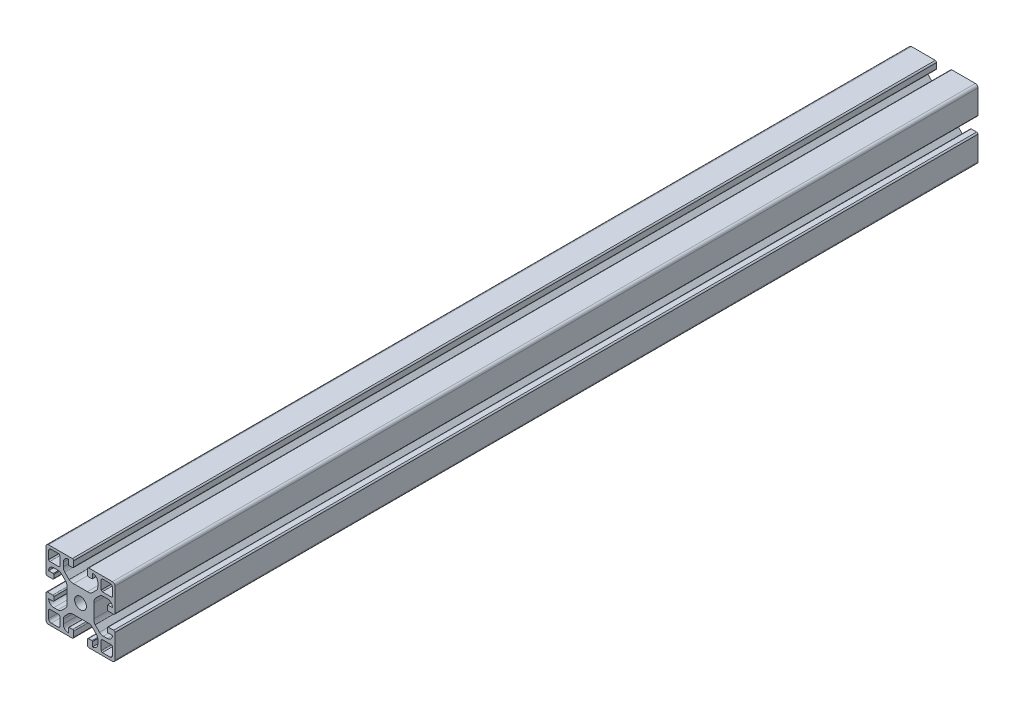
from build123d import *

# Parameters (mm, degrees)
CROQUIS1_R              = 3.4
SALIENTE_EXTRUIR1_DEPTH = 500


with BuildPart() as part:
    # Croquis1 → Saliente-Extruir1 (new body)
    with BuildSketch(Plane.XY):
        with BuildLine():
            ThreePointArc((1.5, 20), (0.439339828, 19.560660172), (0, 18.5))
            Line((0, 18.5), (0, 4.723246277))
            add(Edge.make_bspline(
                [(0, 4.723246277), (0.16818163, 4.15421854), (0.776519027, 4)],
                knots=[0, 0, 0, 1, 1, 1], degree=2))
            Line((0.776519027, 4), (3.876499959, 4))
            add(Edge.make_bspline(
                [(3.876499959, 4), (4.428343851, 4.075321958), (4.5, 4.561581647)],
                knots=[0, 0, 0, 0.770148696, 0.770148696, 0.770148696], degree=2))
            Line((4.5, 4.561581647), (4.5, 4.888433939))
            Line((4.5, 4.888433939), (4.5, 6.675480873))
            add(Edge.make_bspline(
                [(4.226708403, 7), (4.442584391, 6.908044465), (4.5, 6.675480873)],
                knots=[0, 0, 0, 1, 1, 1], degree=2))
            Line((4.226708403, 7), (1.5, 7))
            ThreePointArc((1.5, 7), (2.378679656, 9.121320344), (4.5, 10))
            Line((4.5, 10), (6.795713853, 10))
            add(Edge.make_bspline(
                [(6.795713853, 10), (6.864922078, 10.001348654), (6.933119616, 10)],
                knots=[0, 0, 0, 0.053884422, 0.053884422, 0.053884422], degree=2))
            add(Edge.make_bspline(
                [(6.933119616, 10), (8.130548293, 9.976320018), (9.016390221, 9.121082451)],
                knots=[0.053884422, 0.053884422, 0.053884422, 1, 1, 1], degree=2))
            Line((9.016390221, 9.121082451), (11.507582012, 6.629890661))
            add(Edge.make_bspline(
                [(11.507582012, 6.629890661), (12.156952743, 5.772287934), (12.25, 4.723246277)],
                knots=[0, 0, 0, 0.74933997, 0.74933997, 0.74933997], degree=2))
            add(Edge.make_bspline(
                [(12.25, 4.723246277), (12.281125029, 4.37233371), (12.25, 4)],
                knots=[0.74933997, 0.74933997, 0.74933997, 1, 1, 1], degree=2))
            Line((12.25, 4), (12.25, -4))
            add(Edge.make_bspline(
                [(12.25, -4.723246277), (12.281125029, -4.37233371), (12.25, -4)],
                knots=[0.74933997, 0.74933997, 0.74933997, 1, 1, 1], degree=2))
            add(Edge.make_bspline(
                [(11.507582012, -6.629890661), (12.156952743, -5.772287934), (12.25, -4.723246277)],
                knots=[0, 0, 0, 0.74933997, 0.74933997, 0.74933997], degree=2))
            Line((11.507582012, -6.629890661), (9.016390221, -9.121082451))
            add(Edge.make_bspline(
                [(6.933119616, -10), (8.130548293, -9.976320018), (9.016390221, -9.121082451)],
                knots=[0.053884422, 0.053884422, 0.053884422, 1, 1, 1], degree=2))
            add(Edge.make_bspline(
                [(6.795713853, -10), (6.864922078, -10.001348654), (6.933119616, -10)],
                knots=[0, 0, 0, 0.053884422, 0.053884422, 0.053884422], degree=2))
            Line((6.795713853, -10), (4.5, -10))
            ThreePointArc((4.5, -10), (2.378679656, -9.121320344), (1.5, -7))
            Line((1.5, -7), (4.226708403, -7))
            add(Edge.make_bspline(
                [(4.226708403, -7), (4.442584391, -6.908044465), (4.5, -6.675480873)],
                knots=[0, 0, 0, 1, 1, 1], degree=2))
            Line((4.5, -6.675480873), (4.5, -4.888433939))
            Line((4.5, -4.888433939), (4.5, -4.561581647))
            add(Edge.make_bspline(
                [(3.876499959, -4), (4.428343851, -4.075321958), (4.5, -4.561581647)],
                knots=[0, 0, 0, 0.770148696, 0.770148696, 0.770148696], degree=2))
            Line((3.876499959, -4), (0.776519027, -4))
            add(Edge.make_bspline(
                [(0, -4.723246277), (0.16818163, -4.15421854), (0.776519027, -4)],
                knots=[0, 0, 0, 1, 1, 1], degree=2))
            Line((0, -4.723246277), (0, -18.5))
            ThreePointArc((0, -18.5), (0.439339828, -19.560660172), (1.5, -20))
            Line((1.5, -20), (15.276753723, -20))
            add(Edge.make_bspline(
                [(15.276753723, -20), (15.84578146, -19.83181837), (16, -19.223480973)],
                knots=[0, 0, 0, 1, 1, 1], degree=2))
            Line((16, -19.223480973), (16, -16.123500041))
            add(Edge.make_bspline(
                [(16, -16.123500041), (15.924678042, -15.571656149), (15.438418353, -15.5)],
                knots=[0, 0, 0, 0.770148696, 0.770148696, 0.770148696], degree=2))
            Line((15.438418353, -15.5), (15.111566061, -15.5))
            Line((15.111566061, -15.5), (13.324519127, -15.5))
            add(Edge.make_bspline(
                [(13, -15.773291597), (13.091955535, -15.557415609), (13.324519127, -15.5)],
                knots=[0, 0, 0, 1, 1, 1], degree=2))
            Line((13, -15.773291597), (13, -18.5))
            ThreePointArc((13, -18.5), (10.878679656, -17.621320344), (10, -15.5))
            Line((10, -15.5), (10, -13.204286147))
            add(Edge.make_bspline(
                [(10, -13.204286147), (9.998651346, -13.135077922), (10, -13.066880384)],
                knots=[0, 0, 0, 0.053884422, 0.053884422, 0.053884422], degree=2))
            add(Edge.make_bspline(
                [(10, -13.066880384), (10.023679982, -11.869451707), (10.878917549, -10.983609779)],
                knots=[0.053884422, 0.053884422, 0.053884422, 1, 1, 1], degree=2))
            Line((10.878917549, -10.983609779), (13.370109339, -8.492417988))
            add(Edge.make_bspline(
                [(13.370109339, -8.492417988), (14.227712066, -7.843047257), (15.276753723, -7.75)],
                knots=[0, 0, 0, 0.74933997, 0.74933997, 0.74933997], degree=2))
            add(Edge.make_bspline(
                [(15.276753723, -7.75), (15.62766629, -7.718874971), (16, -7.75)],
                knots=[0.74933997, 0.74933997, 0.74933997, 1, 1, 1], degree=2))
            Line((16, -7.75), (24, -7.75))
            add(Edge.make_bspline(
                [(24.723246277, -7.75), (24.37233371, -7.718874971), (24, -7.75)],
                knots=[0.74933997, 0.74933997, 0.74933997, 1, 1, 1], degree=2))
            add(Edge.make_bspline(
                [(26.629890661, -8.492417988), (25.772287934, -7.843047257), (24.723246277, -7.75)],
                knots=[0, 0, 0, 0.74933997, 0.74933997, 0.74933997], degree=2))
            Line((26.629890661, -8.492417988), (29.121082451, -10.983609779))
            add(Edge.make_bspline(
                [(30, -13.066880384), (29.976320018, -11.869451707), (29.121082451, -10.983609779)],
                knots=[0.053884422, 0.053884422, 0.053884422, 1, 1, 1], degree=2))
            add(Edge.make_bspline(
                [(30, -13.204286147), (30.001348654, -13.135077922), (30, -13.066880384)],
                knots=[0, 0, 0, 0.053884422, 0.053884422, 0.053884422], degree=2))
            Line((30, -13.204286147), (30, -15.5))
            ThreePointArc((30, -15.5), (29.121320344, -17.621320344), (27, -18.5))
            Line((27, -18.5), (27, -15.773291597))
            add(Edge.make_bspline(
                [(27, -15.773291597), (26.908044465, -15.557415609), (26.675480873, -15.5)],
                knots=[0, 0, 0, 1, 1, 1], degree=2))
            Line((26.675480873, -15.5), (24.888433939, -15.5))
            Line((24.888433939, -15.5), (24.561581647, -15.5))
            add(Edge.make_bspline(
                [(24, -16.123500041), (24.075321958, -15.571656149), (24.561581647, -15.5)],
                knots=[0, 0, 0, 0.770148696, 0.770148696, 0.770148696], degree=2))
            Line((24, -16.123500041), (24, -19.223480973))
            add(Edge.make_bspline(
                [(24.723246277, -20), (24.15421854, -19.83181837), (24, -19.223480973)],
                knots=[0, 0, 0, 1, 1, 1], degree=2))
            Line((24.723246277, -20), (38.5, -20))
            ThreePointArc((38.5, -20), (39.560660172, -19.560660172), (40, -18.5))
            Line((40, -18.5), (40, -4.723246277))
            add(Edge.make_bspline(
                [(40, -4.723246277), (39.83181837, -4.15421854), (39.223480973, -4)],
                knots=[0, 0, 0, 1, 1, 1], degree=2))
            Line((39.223480973, -4), (36.123500041, -4))
            add(Edge.make_bspline(
                [(36.123500041, -4), (35.571656149, -4.075321958), (35.5, -4.561581647)],
                knots=[0, 0, 0, 0.770148696, 0.770148696, 0.770148696], degree=2))
            Line((35.5, -4.561581647), (35.5, -4.888433939))
            Line((35.5, -4.888433939), (35.5, -6.675480873))
            add(Edge.make_bspline(
                [(35.773291597, -7), (35.557415609, -6.908044465), (35.5, -6.675480873)],
                knots=[0, 0, 0, 1, 1, 1], degree=2))
            Line((35.773291597, -7), (38.5, -7))
            ThreePointArc((38.5, -7), (37.621320344, -9.121320344), (35.5, -10))
            Line((35.5, -10), (33.204286147, -10))
            add(Edge.make_bspline(
                [(33.204286147, -10), (33.135077922, -10.001348654), (33.066880384, -10)],
                knots=[0, 0, 0, 0.053884422, 0.053884422, 0.053884422], degree=2))
            add(Edge.make_bspline(
                [(33.066880384, -10), (31.869451707, -9.976320018), (30.983609779, -9.121082451)],
                knots=[0.053884422, 0.053884422, 0.053884422, 1, 1, 1], degree=2))
            Line((30.983609779, -9.121082451), (28.492417988, -6.629890661))
            add(Edge.make_bspline(
                [(28.492417988, -6.629890661), (27.843047257, -5.772287934), (27.75, -4.723246277)],
                knots=[0, 0, 0, 0.74933997, 0.74933997, 0.74933997], degree=2))
            add(Edge.make_bspline(
                [(27.75, -4.723246277), (27.718874971, -4.37233371), (27.75, -4)],
                knots=[0.74933997, 0.74933997, 0.74933997, 1, 1, 1], degree=2))
            Line((27.75, -4), (27.75, 4))
            add(Edge.make_bspline(
                [(27.75, 4.723246277), (27.718874971, 4.37233371), (27.75, 4)],
                knots=[0.74933997, 0.74933997, 0.74933997, 1, 1, 1], degree=2))
            add(Edge.make_bspline(
                [(28.492417988, 6.629890661), (27.843047257, 5.772287934), (27.75, 4.723246277)],
                knots=[0, 0, 0, 0.74933997, 0.74933997, 0.74933997], degree=2))
            Line((28.492417988, 6.629890661), (30.983609779, 9.121082451))
            add(Edge.make_bspline(
                [(33.066880384, 10), (31.869451707, 9.976320018), (30.983609779, 9.121082451)],
                knots=[0.053884422, 0.053884422, 0.053884422, 1, 1, 1], degree=2))
            add(Edge.make_bspline(
                [(33.204286147, 10), (33.135077922, 10.001348654), (33.066880384, 10)],
                knots=[0, 0, 0, 0.053884422, 0.053884422, 0.053884422], degree=2))
            Line((33.204286147, 10), (35.5, 10))
            ThreePointArc((35.5, 10), (37.621320344, 9.121320344), (38.5, 7))
            Line((38.5, 7), (35.773291597, 7))
            add(Edge.make_bspline(
                [(35.773291597, 7), (35.557415609, 6.908044465), (35.5, 6.675480873)],
                knots=[0, 0, 0, 1, 1, 1], degree=2))
            Line((35.5, 6.675480873), (35.5, 4.888433939))
            Line((35.5, 4.888433939), (35.5, 4.561581647))
            add(Edge.make_bspline(
                [(36.123500041, 4), (35.571656149, 4.075321958), (35.5, 4.561581647)],
                knots=[0, 0, 0, 0.770148696, 0.770148696, 0.770148696], degree=2))
            Line((36.123500041, 4), (39.223480973, 4))
            add(Edge.make_bspline(
                [(40, 4.723246277), (39.83181837, 4.15421854), (39.223480973, 4)],
                knots=[0, 0, 0, 1, 1, 1], degree=2))
            Line((40, 4.723246277), (40, 18.5))
            ThreePointArc((40, 18.5), (39.560660172, 19.560660172), (38.5, 20))
            Line((38.5, 20), (24.723246277, 20))
            add(Edge.make_bspline(
                [(24.723246277, 20), (24.15421854, 19.83181837), (24, 19.223480973)],
                knots=[0, 0, 0, 1, 1, 1], degree=2))
            Line((24, 19.223480973), (24, 16.123500041))
            add(Edge.make_bspline(
                [(24, 16.123500041), (24.075321958, 15.571656149), (24.561581647, 15.5)],
                knots=[0, 0, 0, 0.770148696, 0.770148696, 0.770148696], degree=2))
            Line((24.561581647, 15.5), (24.888433939, 15.5))
            Line((24.888433939, 15.5), (26.675480873, 15.5))
            add(Edge.make_bspline(
                [(27, 15.773291597), (26.908044465, 15.557415609), (26.675480873, 15.5)],
                knots=[0, 0, 0, 1, 1, 1], degree=2))
            Line((27, 15.773291597), (27, 18.5))
            ThreePointArc((27, 18.5), (29.121320344, 17.621320344), (30, 15.5))
            Line((30, 15.5), (30, 13.204286147))
            add(Edge.make_bspline(
                [(30, 13.204286147), (30.001348654, 13.135077922), (30, 13.066880384)],
                knots=[0, 0, 0, 0.053884422, 0.053884422, 0.053884422], degree=2))
            add(Edge.make_bspline(
                [(30, 13.066880384), (29.976320018, 11.869451707), (29.121082451, 10.983609779)],
                knots=[0.053884422, 0.053884422, 0.053884422, 1, 1, 1], degree=2))
            Line((29.121082451, 10.983609779), (26.629890661, 8.492417988))
            add(Edge.make_bspline(
                [(26.629890661, 8.492417988), (25.772287934, 7.843047257), (24.723246277, 7.75)],
                knots=[0, 0, 0, 0.74933997, 0.74933997, 0.74933997], degree=2))
            add(Edge.make_bspline(
                [(24.723246277, 7.75), (24.37233371, 7.718874971), (24, 7.75)],
                knots=[0.74933997, 0.74933997, 0.74933997, 1, 1, 1], degree=2))
            Line((24, 7.75), (16, 7.75))
            add(Edge.make_bspline(
                [(15.276753723, 7.75), (15.62766629, 7.718874971), (16, 7.75)],
                knots=[0.74933997, 0.74933997, 0.74933997, 1, 1, 1], degree=2))
            add(Edge.make_bspline(
                [(13.370109339, 8.492417988), (14.227712066, 7.843047257), (15.276753723, 7.75)],
                knots=[0, 0, 0, 0.74933997, 0.74933997, 0.74933997], degree=2))
            Line((13.370109339, 8.492417988), (10.878917549, 10.983609779))
            add(Edge.make_bspline(
                [(10, 13.066880384), (10.023679982, 11.869451707), (10.878917549, 10.983609779)],
                knots=[0.053884422, 0.053884422, 0.053884422, 1, 1, 1], degree=2))
            add(Edge.make_bspline(
                [(10, 13.204286147), (9.998651346, 13.135077922), (10, 13.066880384)],
                knots=[0, 0, 0, 0.053884422, 0.053884422, 0.053884422], degree=2))
            Line((10, 13.204286147), (10, 15.5))
            ThreePointArc((10, 15.5), (10.878679656, 17.621320344), (13, 18.5))
            Line((13, 18.5), (13, 15.773291597))
            add(Edge.make_bspline(
                [(13, 15.773291597), (13.091955535, 15.557415609), (13.324519127, 15.5)],
                knots=[0, 0, 0, 1, 1, 1], degree=2))
            Line((13.324519127, 15.5), (15.111566061, 15.5))
            Line((15.111566061, 15.5), (15.438418353, 15.5))
            add(Edge.make_bspline(
                [(16, 16.123500041), (15.924678042, 15.571656149), (15.438418353, 15.5)],
                knots=[0, 0, 0, 0.770148696, 0.770148696, 0.770148696], degree=2))
            Line((16, 16.123500041), (16, 19.223480973))
            add(Edge.make_bspline(
                [(15.276753723, 20), (15.84578146, 19.83181837), (16, 19.223480973)],
                knots=[0, 0, 0, 1, 1, 1], degree=2))
            Line((15.276753723, 20), (1.5, 20))
        make_face()
        with BuildLine():
            add(Edge.make_bspline(
                [(7.381658877, -18.5), (7.954867262, -18.386704516), (8, -17.770035709)],
                knots=[0, 0, 0, 1, 1, 1], degree=2))
            Line((7.381658877, -18.5), (3, -18.5))
            ThreePointArc((3, -18.5), (1.939339828, -18.060660172), (1.5, -17))
            Line((1.5, -17), (1.5, -12.618341123))
            add(Edge.make_bspline(
                [(1.5, -12.618341123), (1.613295484, -12.045132738), (2.229964291, -12)],
                knots=[0, 0, 0, 1, 1, 1], degree=2))
            Line((2.229964291, -12), (5.716559808, -12))
            Line((5.716559808, -12), (7.381658877, -12))
            add(Edge.make_bspline(
                [(7.381658877, -12), (7.910058331, -12.07521512), (8, -12.618341123)],
                knots=[0, 0, 0, 1, 1, 1], degree=2))
            Line((8, -12.618341123), (8, -14.283440192))
            Line((8, -14.283440192), (8, -17.770035709))
        make_face(mode=Mode.SUBTRACT)
        with BuildLine():
            Line((32.618341123, -12), (34.283440192, -12))
            Line((34.283440192, -12), (37.770035709, -12))
            add(Edge.make_bspline(
                [(38.5, -12.618341123), (38.386704516, -12.045132738), (37.770035709, -12)],
                knots=[0, 0, 0, 1, 1, 1], degree=2))
            Line((38.5, -12.618341123), (38.5, -17))
            ThreePointArc((38.5, -17), (38.060660172, -18.060660172), (37, -18.5))
            Line((37, -18.5), (32.618341123, -18.5))
            add(Edge.make_bspline(
                [(32.618341123, -18.5), (32.045132738, -18.386704516), (32, -17.770035709)],
                knots=[0, 0, 0, 1, 1, 1], degree=2))
            Line((32, -17.770035709), (32, -14.283440192))
            Line((32, -14.283440192), (32, -12.618341123))
            add(Edge.make_bspline(
                [(32.618341123, -12), (32.089941669, -12.07521512), (32, -12.618341123)],
                knots=[0, 0, 0, 1, 1, 1], degree=2))
        make_face(mode=Mode.SUBTRACT)
        with Locations((20, 0)):
            Circle(CROQUIS1_R, mode=Mode.SUBTRACT)
        with BuildLine():
            Line((7.381658877, 12), (5.716559808, 12))
            Line((5.716559808, 12), (2.229964291, 12))
            add(Edge.make_bspline(
                [(1.5, 12.618341123), (1.613295484, 12.045132738), (2.229964291, 12)],
                knots=[0, 0, 0, 1, 1, 1], degree=2))
            Line((1.5, 12.618341123), (1.5, 17))
            ThreePointArc((1.5, 17), (1.939339828, 18.060660172), (3, 18.5))
            Line((3, 18.5), (7.381658877, 18.5))
            add(Edge.make_bspline(
                [(7.381658877, 18.5), (7.954867262, 18.386704516), (8, 17.770035709)],
                knots=[0, 0, 0, 1, 1, 1], degree=2))
            Line((8, 17.770035709), (8, 14.283440192))
            Line((8, 14.283440192), (8, 12.618341123))
            add(Edge.make_bspline(
                [(7.381658877, 12), (7.910058331, 12.07521512), (8, 12.618341123)],
                knots=[0, 0, 0, 1, 1, 1], degree=2))
        make_face(mode=Mode.SUBTRACT)
        with BuildLine():
            add(Edge.make_bspline(
                [(32.618341123, 18.5), (32.045132738, 18.386704516), (32, 17.770035709)],
                knots=[0, 0, 0, 1, 1, 1], degree=2))
            Line((32.618341123, 18.5), (37, 18.5))
            ThreePointArc((37, 18.5), (38.060660172, 18.060660172), (38.5, 17))
            Line((38.5, 17), (38.5, 12.618341123))
            add(Edge.make_bspline(
                [(38.5, 12.618341123), (38.386704516, 12.045132738), (37.770035709, 12)],
                knots=[0, 0, 0, 1, 1, 1], degree=2))
            Line((37.770035709, 12), (34.283440192, 12))
            Line((34.283440192, 12), (32.618341123, 12))
            add(Edge.make_bspline(
                [(32.618341123, 12), (32.089941669, 12.07521512), (32, 12.618341123)],
                knots=[0, 0, 0, 1, 1, 1], degree=2))
            Line((32, 12.618341123), (32, 14.283440192))
            Line((32, 14.283440192), (32, 17.770035709))
        make_face(mode=Mode.SUBTRACT)
    extrude(amount=SALIENTE_EXTRUIR1_DEPTH)


solid = part.part
